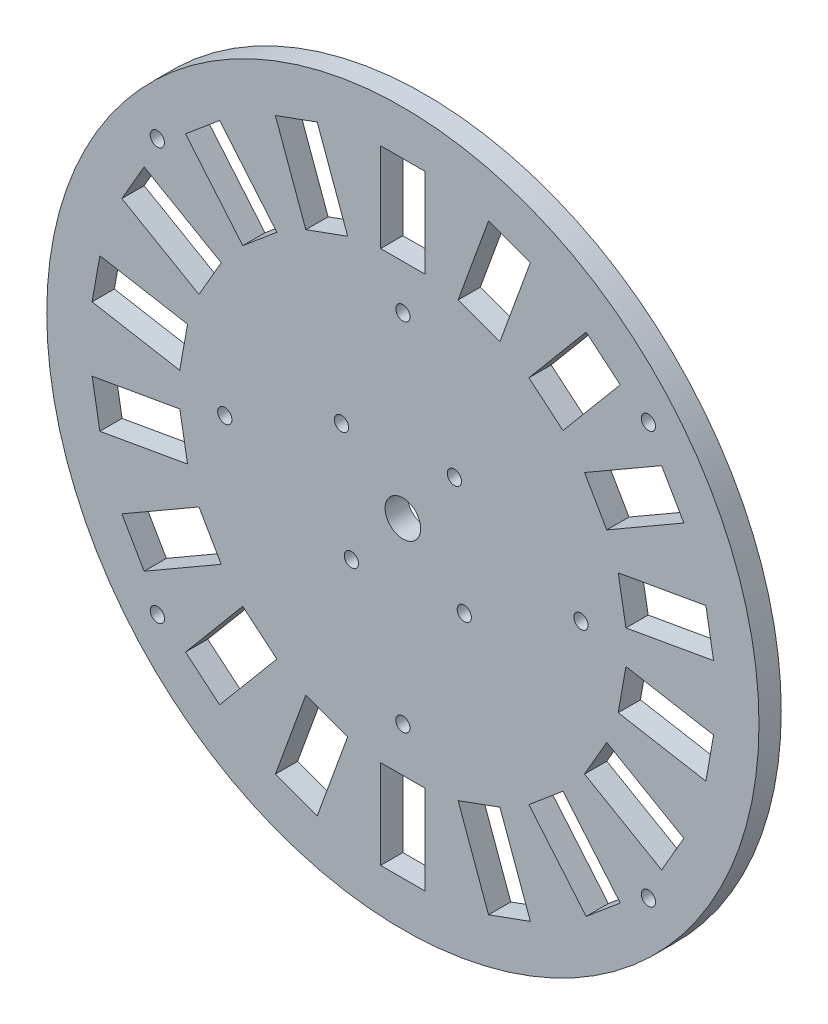
from build123d import *

# Parameters (mm, degrees)
SKETCH1_R           = 80
BOSS_EXTRUDE1_DEPTH = 5
SKETCH2_R           = 4
SKETCH2_W           = 10
SKETCH2_H           = 20
CUT_EXTRUDE1_DEPTH  = 5
CIRPATTERN1_COUNT   = 18
SKETCH3_R           = 1.6
CUT_EXTRUDE2_DEPTH  = 5
SKETCH4_R           = 1.6
CUT_EXTRUDE3_DEPTH  = 10


with BuildPart() as part:
    # Sketch1 → Boss-Extrude1 (new body)
    with BuildSketch(Plane.XY):
        Circle(SKETCH1_R)
    extrude(amount=BOSS_EXTRUDE1_DEPTH)

    # Sketch2 → Cut-Extrude1 (cut)
    with BuildSketch(Plane.XY.offset(5)):
        Circle(SKETCH2_R)
        with Locations((0, 60)):
            Rectangle(SKETCH2_W, SKETCH2_H)
    cut_extrude1 = extrude(amount=-CUT_EXTRUDE1_DEPTH, mode=Mode.SUBTRACT)

    # CirPattern1: Cut-Extrude1 ×18 about axis
    cirpattern1_axis = Axis((0, 0, 0), (0, 0, 1))
    for i in range(1, CIRPATTERN1_COUNT):
        add(cut_extrude1.rotate(cirpattern1_axis, i * 360 / CIRPATTERN1_COUNT), mode=Mode.SUBTRACT)

    # Sketch3 → Cut-Extrude2 (cut)
    with BuildSketch(Plane.XY.offset(5)):
        with Locations((-55.155199905, 46.280707897)):
            Circle(SKETCH3_R)
        with Locations((-55.155199905, -46.280707897)):
            Circle(SKETCH3_R)
        with Locations((55.155199905, -46.280707897)):
            Circle(SKETCH3_R)
        with Locations((55.155199905, 46.280707897)):
            Circle(SKETCH3_R)
        with Locations((-40, 0)):
            Circle(SKETCH3_R)
        with Locations((0, 40)):
            Circle(SKETCH3_R)
        with Locations((0, -40)):
            Circle(SKETCH3_R)
        with Locations((40, 0)):
            Circle(SKETCH3_R)
    extrude(amount=-CUT_EXTRUDE2_DEPTH, mode=Mode.SUBTRACT)

    # Sketch4 → Cut-Extrude3 (cut)
    with BuildSketch(Plane(origin=(0, 0, 0), x_dir=(-1, 0, 0), z_dir=(0, 0, -1))):
        with Locations((-11.570176974, 13.788799976)):
            Circle(SKETCH4_R)
        with Locations((13.788799976, 11.570176974)):
            Circle(SKETCH4_R)
        with Locations((11.570176974, -13.788799976)):
            Circle(SKETCH4_R)
        with Locations((-13.788799976, -11.570176974)):
            Circle(SKETCH4_R)
    extrude(amount=-CUT_EXTRUDE3_DEPTH, mode=Mode.SUBTRACT)


solid = part.part
